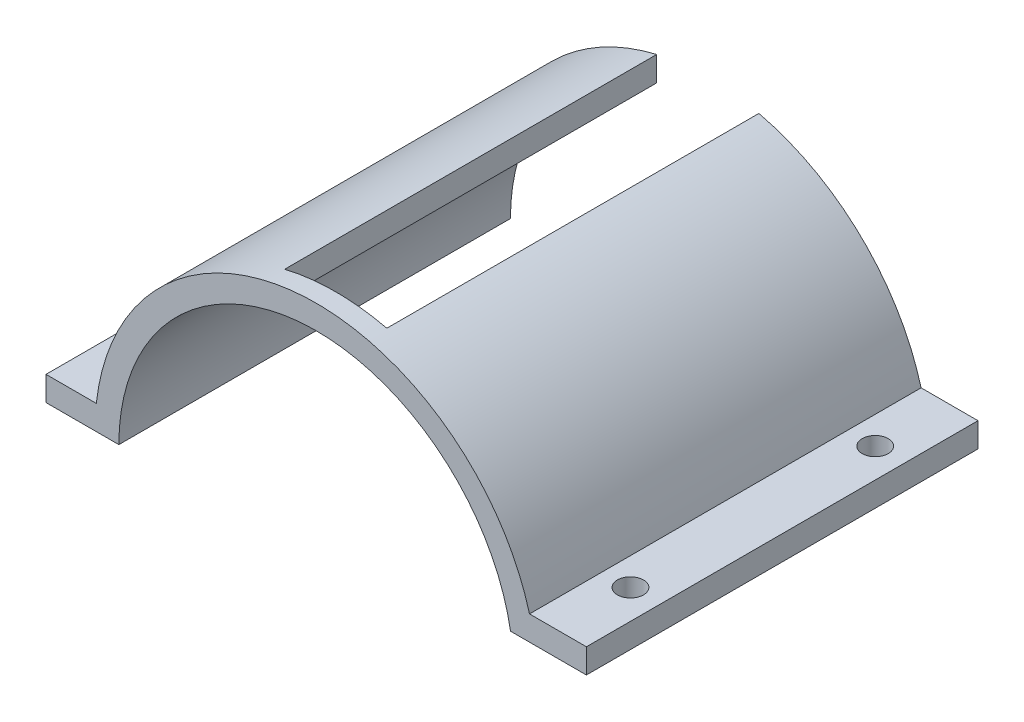
from build123d import *

# Parameters (mm, degrees)
BOSS_EXTRUDE1_DEPTH     = 50.8
BOSS_EXTRUDE1_2_DEPTH   = 50.8
BOSS_EXTRUDE2_START     = 50.8
BOSS_EXTRUDE2_DEPTH     = 5.08
F_1_4_CLEARANCE_HOLE1_D = 6.7564
F_1_4_CLEARANCE_HOLE2_D = 6.7564


with BuildPart() as part:
    # Sketch1 → Boss-Extrude1 (new body, symmetric)
    with BuildSketch(Plane.XY):
        with BuildLine():
            ThreePointArc((-13.252570374, 55.853277384), (-42.992049277, 38.038177072), (-57.051702131, 6.35))
            Line((-57.051702131, 6.35), (-70.104, 6.35))
            Line((-70.104, 6.35), (-70.104, 0))
            Line((-70.104, 0), (-51.203999954, 0))
            ThreePointArc((-51.203999954, 0), (-40.6228644, 31.171020183), (-13.252570374, 49.459265965))
            Line((-13.252570374, 49.459265965), (-13.252570374, 55.853277384))
        make_face()
    extrude(amount=BOSS_EXTRUDE1_DEPTH, both=True)



with BuildPart() as body_2:
    # Sketch1 → Boss-Extrude1 2 (new body, symmetric)
    with BuildSketch(Plane.XY):
        with BuildLine():
            Line((13.252570374, 55.853277384), (13.252570374, 49.459265965))
            ThreePointArc((13.252570374, 49.459265965), (37.75154872, 34.59292096), (50.42609614, 8.891481281))
            Line((50.42609614, 8.891481281), (70.104, 8.891481281))
            Line((70.104, 8.891481281), (70.104, 15.241481281))
            Line((70.104, 15.241481281), (55.343621713, 15.241481281))
            ThreePointArc((55.343621713, 15.241481281), (39.858360326, 41.310172211), (13.252570374, 55.853277384))
        make_face()
    extrude(amount=BOSS_EXTRUDE1_2_DEPTH, both=True)


with BuildPart() as part_1:
    add(part.part)

    add(body_2.part)  # Boss-Extrude2 merges body 2
    # Sketch1_4 → Boss-Extrude2 (add)
    with BuildSketch(Plane.XY.offset(BOSS_EXTRUDE2_START)):
        with BuildLine():
            Line((-13.252570374, 55.853277384), (-13.252570374, 49.459265965))
            ThreePointArc((-13.252570374, 49.459265965), (0, 51.203999954), (13.252570374, 49.459265965))
            Line((13.252570374, 49.459265965), (13.252570374, 55.853277384))
            ThreePointArc((13.252570374, 55.853277384), (0, 57.404), (-13.252570374, 55.853277384))
        make_face()
    extrude(amount=-BOSS_EXTRUDE2_DEPTH)

    # 1_4 Clearance Hole1 (through all)
    with Locations(Plane(origin=(0, 6.35, 0), x_dir=(1, 0, 0), z_dir=(0, 1, 0))):
        with Locations((-62.484, -31.75), (-62.484, 31.75)):
            Hole(F_1_4_CLEARANCE_HOLE1_D / 2)

    # 1_4 Clearance Hole2 (through all)
    with Locations(Plane(origin=(0, 15.241481281, 0), x_dir=(1, 0, 0), z_dir=(0, 1, 0))):
        with Locations((62.484, -31.75), (62.484, 31.75)):
            Hole(F_1_4_CLEARANCE_HOLE2_D / 2)


solid = part_1.part
